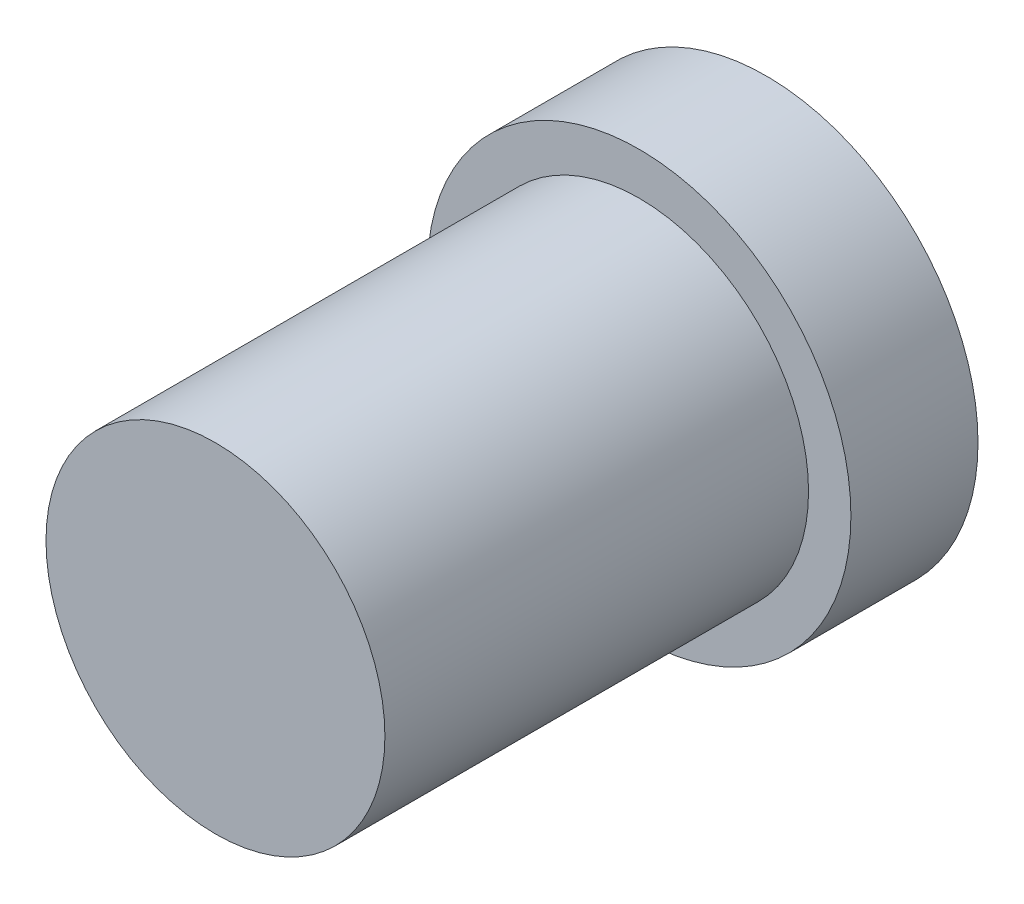
from build123d import *

# Parameters (mm, degrees)
SKETCH1_R           = 5
BOSS_EXTRUDE1_DEPTH = 3
SKETCH2_R           = 4
BOSS_EXTRUDE2_DEPTH = 10


with BuildPart() as part:
    # Sketch1 → Boss-Extrude1 (new body)
    with BuildSketch(Plane.XY):
        Circle(SKETCH1_R)
    extrude(amount=BOSS_EXTRUDE1_DEPTH)

    # Sketch2 → Boss-Extrude2 (add)
    with BuildSketch(Plane.XY.offset(3)):
        Circle(SKETCH2_R)
    extrude(amount=BOSS_EXTRUDE2_DEPTH)


solid = part.part
